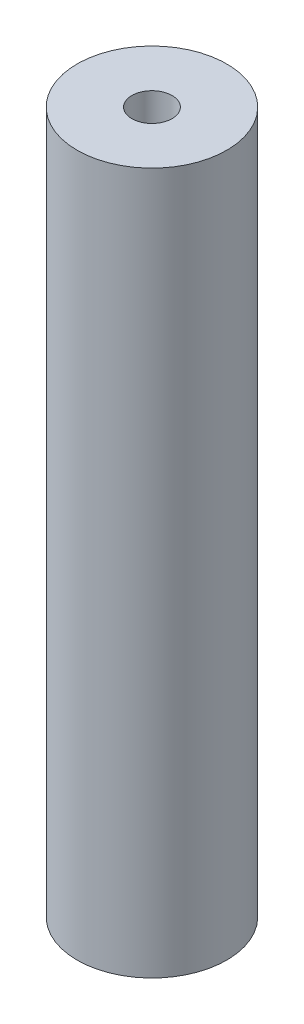
from build123d import *

# Parameters (mm, degrees)
CROQUIS1_R              = 16
CROQUIS1_R_2            = 4.3
SALIENTE_EXTRUIR1_DEPTH = 150


with BuildPart() as part:
    # Croquis1 → Saliente-Extruir1 (new body)
    with BuildSketch(Plane(origin=(0, 0, 0), x_dir=(1, 0, 0), z_dir=(0, 1, 0))):
        Circle(CROQUIS1_R)
        Circle(CROQUIS1_R_2, mode=Mode.SUBTRACT)
    extrude(amount=SALIENTE_EXTRUIR1_DEPTH)


solid = part.part
